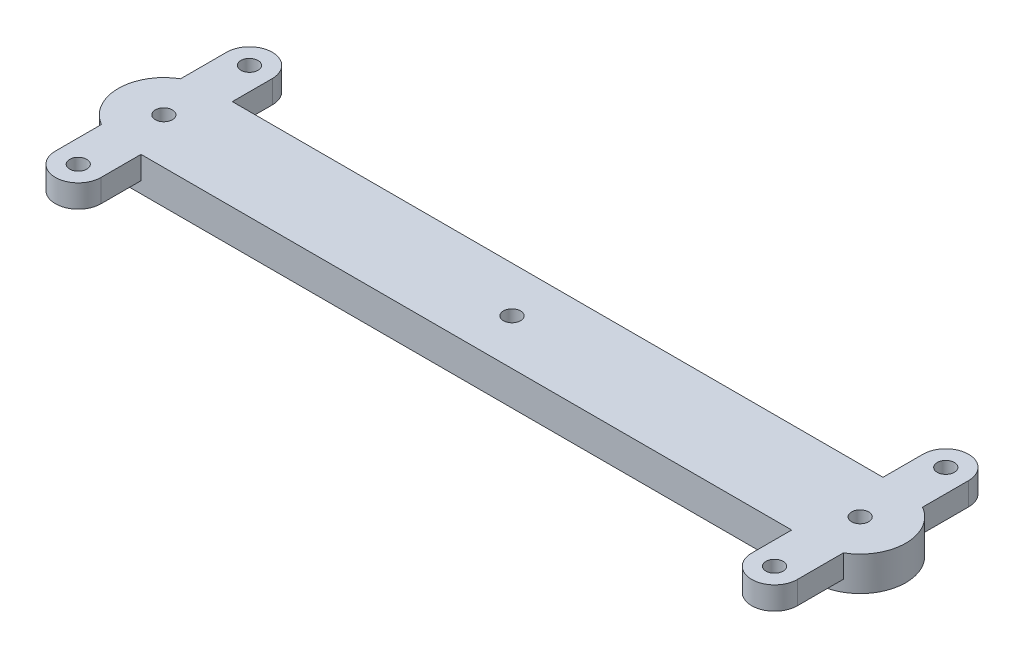
from build123d import *

# Parameters (mm, degrees)
SKETCH1_R           = 1.5
BOSS_EXTRUDE1_DEPTH = 6
SKETCH2_R           = 1.5
BOSS_EXTRUDE2_DEPTH = 4
SKETCH3_R           = 1.5
CUT_EXTRUDE1_DEPTH  = 10


with BuildPart() as part:
    # Sketch1 → Boss-Extrude1 (new body)
    with BuildSketch(Plane(origin=(0, 0, 0), x_dir=(1, 0, 0), z_dir=(0, 1, 0))):
        with BuildLine():
            Line((0, 8), (122, 8))
            ThreePointArc((122, 8), (130, 0), (122, -8))
            Line((122, -8), (0, -8))
            ThreePointArc((0, -8), (-8, 0), (0, 8))
        make_face()
        Circle(SKETCH1_R, mode=Mode.SUBTRACT)
        with Locations((122, 0)):
            Circle(SKETCH1_R, mode=Mode.SUBTRACT)
    extrude(amount=BOSS_EXTRUDE1_DEPTH)

    # Sketch2 → Boss-Extrude2 (add)
    with BuildSketch(Plane(origin=(0, 6, 0), x_dir=(1, 0, 0), z_dir=(0, 1, 0))):
        with BuildLine():
            Line((4, 8), (4, 15))
            ThreePointArc((4, 15), (0, 19), (-4, 15))
            Line((-4, 15), (-4, 6.92820323))
            ThreePointArc((-4, 6.92820323), (-2.070552361, 7.72740661), (0, 8))
            Line((0, 8), (4, 8))
        make_face()
        with Locations((0, 15)):
            Circle(SKETCH2_R, mode=Mode.SUBTRACT)
        with BuildLine():
            Line((4, -15), (4, -8))
            Line((4, -8), (0, -8))
            ThreePointArc((0, -8), (-2.070552361, -7.72740661), (-4, -6.92820323))
            Line((-4, -6.92820323), (-4, -15))
            ThreePointArc((-4, -15), (0, -19), (4, -15))
        make_face()
        with Locations((0, -15)):
            Circle(SKETCH2_R, mode=Mode.SUBTRACT)
        with BuildLine():
            Line((118, 15), (118, 8))
            Line((118, 8), (122, 8))
            ThreePointArc((122, 8), (124.070552361, 7.72740661), (126, 6.92820323))
            Line((126, 6.92820323), (126, 15))
            ThreePointArc((126, 15), (122, 19), (118, 15))
        make_face()
        with Locations((122, 15)):
            Circle(SKETCH2_R, mode=Mode.SUBTRACT)
        with BuildLine():
            Line((122, -8), (118, -8))
            Line((118, -8), (118, -15))
            ThreePointArc((118, -15), (122, -19), (126, -15))
            Line((126, -15), (126, -6.92820323))
            ThreePointArc((126, -6.92820323), (124.070552361, -7.72740661), (122, -8))
        make_face()
        with Locations((122, -15)):
            Circle(SKETCH2_R, mode=Mode.SUBTRACT)
    extrude(amount=-BOSS_EXTRUDE2_DEPTH)

    # Sketch3 → Cut-Extrude1 (cut)
    with BuildSketch(Plane(origin=(0, 6, 0), x_dir=(1, 0, 0), z_dir=(0, 1, 0))):
        with Locations((61, 0)):
            Circle(SKETCH3_R)
    extrude(amount=-CUT_EXTRUDE1_DEPTH, mode=Mode.SUBTRACT)


solid = part.part
